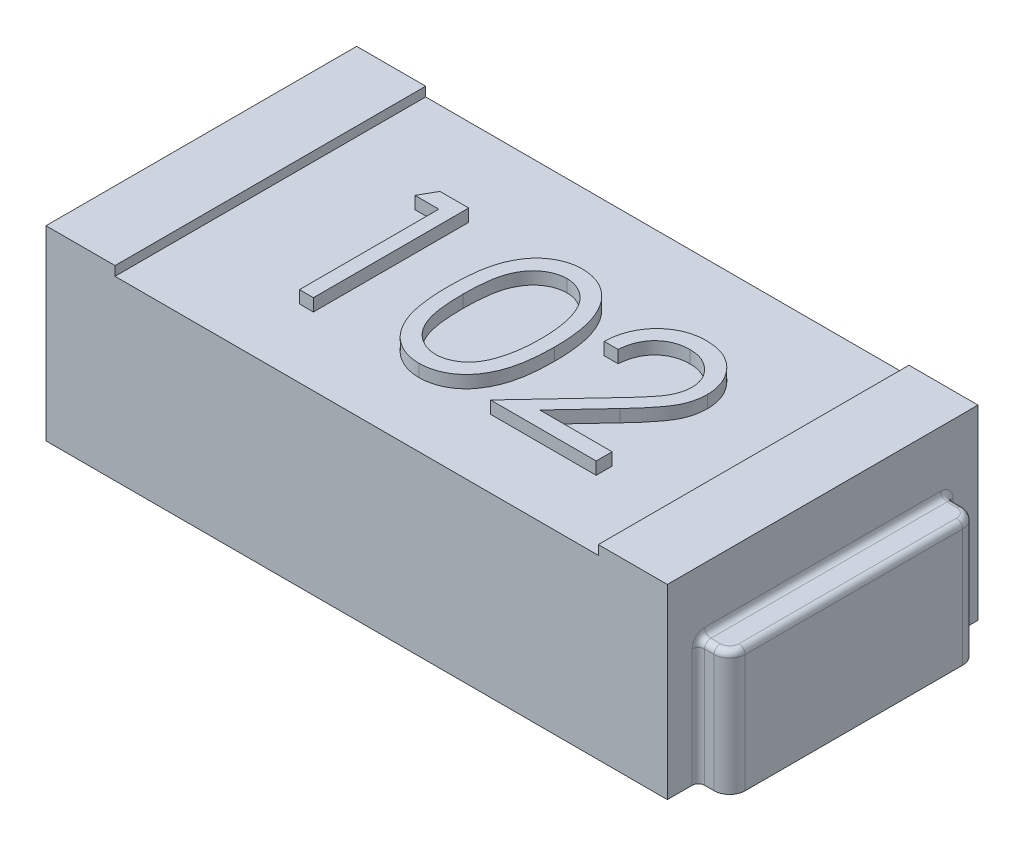
from build123d import *

# Parameters (mm, degrees)
ESQUISSE1_W             = 2
ESQUISSE1_H             = 1
BOSS_EXTRU_1_DEPTH      = 0.6
ESQUISSE2_W             = 1.555645222
ESQUISSE2_H             = 1
ENL_V_MAT_EXTRU_1_DEPTH = 0.03
BOSS_EXTRU_2_DEPTH      = 0.4
CONG_1_R                = 0.02
CONG_1_OF_SYM_TRIE2_R   = 0.02
BOSS_EXTRU_3_DEPTH      = 0.04


with BuildPart() as part:
    # Esquisse1 → Boss.-Extru.1 (new body)
    with BuildSketch(Plane(origin=(0, 0, 0), x_dir=(1, 0, 0), z_dir=(0, 1, 0))):
        Rectangle(ESQUISSE1_W, ESQUISSE1_H)
    extrude(amount=BOSS_EXTRU_1_DEPTH)

    # Esquisse2 → Enlèv. mat.-Extru.1 (cut)
    with BuildSketch(Plane(origin=(0, 0.6, 0), x_dir=(1, 0, 0), z_dir=(0, 1, 0))):
        Rectangle(ESQUISSE2_W, ESQUISSE2_H)
    extrude(amount=-ENL_V_MAT_EXTRU_1_DEPTH, mode=Mode.SUBTRACT)

    # Esquisse3 → Boss.-Extru.2 (add)
    with BuildSketch(Plane(origin=(0, 0, 0), x_dir=(1, 0, 0), z_dir=(0, 1, 0))):
        with BuildLine():
            Line((1, 0.4), (1.050552667, 0.4))
            ThreePointArc((1.050552667, 0.4), (1.085908006, 0.385355339), (1.100552667, 0.35))
            Line((1.100552667, 0.35), (1.100552667, -0.35))
            ThreePointArc((1.100552667, -0.35), (1.085908006, -0.385355339), (1.050552667, -0.4))
            Line((1.050552667, -0.4), (1, -0.4))
            Line((1, -0.4), (1, 0.4))
        make_face()
    boss_extru_2 = extrude(amount=BOSS_EXTRU_2_DEPTH)

    # Congé1
    cong_1_edges = [part.edges().sort_by_distance(p)[0] for p in [
        (1, 0.2, -0.4),
        (1, 0.2, 0.4),
        (1, 0.4, 0),
        (1.025276334, 0.4, 0.4),
        (1.085908006, 0.4, 0.385355339),
        (1.100552667, 0.4, 0),
        (1.085908006, 0.4, -0.385355339),
        (1.025276334, 0.4, -0.4),
    ]]
    fillet(cong_1_edges, radius=CONG_1_R)

    # Symétrie2: Boss.-Extru.2 across plane
    add(boss_extru_2.mirror(Plane(origin=(0, 0, 0), x_dir=(0, 0, 1), z_dir=(1, 0, 0))))

    # Congé1 of Symétrie2
    cong_1_of_sym_trie2_edges = [part.edges().sort_by_distance(p)[0] for p in [
        (-1, 0.2, -0.4),
        (-1, 0.2, 0.4),
        (-1, 0.4, 0),
        (-1.025276334, 0.4, 0.4),
        (-1.085908006, 0.4, 0.385355339),
        (-1.100552667, 0.4, 0),
        (-1.085908006, 0.4, -0.385355339),
        (-1.025276334, 0.4, -0.4),
    ]]
    fillet(cong_1_of_sym_trie2_edges, radius=CONG_1_OF_SYM_TRIE2_R)

    # Esquisse4 → Boss.-Extru.3 (add)
    with BuildSketch(Plane(origin=(0, 0.57, 0), x_dir=(1, 0, 0), z_dir=(0, 1, 0))):
        with BuildLine():
            Line((0.275641026, 0.065854324), (0.230769231, 0.065854324))
            add(Edge.make_bspline(
                [(0.230769231, 0.065854324), (0.231061681, 0.071807307), (0.231636046, 0.08349881), (0.234325802, 0.100545082), (0.238174498, 0.116838625), (0.243616135, 0.132248612), (0.250374174, 0.146911299), (0.258478464, 0.160768444), (0.268077586, 0.173767185), (0.278964262, 0.18578702), (0.290788353, 0.196813816), (0.303546344, 0.206335994), (0.316952777, 0.214381375), (0.330966977, 0.221107267), (0.345747057, 0.226155816), (0.361158894, 0.229901765), (0.377270199, 0.232155528), (0.388247345, 0.232397784), (0.393830128, 0.23252099)],
                knots=[0, 0, 0, 0, 1.7869e-05, 3.5094e-05, 5.1686e-05, 6.8032e-05, 8.4031e-05, 0.000100058, 0.000116104, 0.000132416, 0.000148647, 0.000164532, 0.000180078, 0.00019549, 0.000211074, 0.000226841, 0.000243017, 0.000259759, 0.000259759, 0.000259759, 0.000259759], degree=3))
            add(Edge.make_bspline(
                [(0.393830128, 0.23252099), (0.39931271, 0.232392639), (0.410085788, 0.232140434), (0.425808933, 0.229974573), (0.440777118, 0.226582346), (0.454961085, 0.221823), (0.468247665, 0.215425225), (0.480736672, 0.207739862), (0.492576787, 0.198851315), (0.503234899, 0.188386485), (0.513021768, 0.177214715), (0.521464947, 0.165287872), (0.528695399, 0.152969403), (0.53472221, 0.140165374), (0.539158802, 0.126755227), (0.542527117, 0.112934198), (0.544431033, 0.098559225), (0.544723237, 0.088829717), (0.544871795, 0.08388317)],
                knots=[0, 0, 0, 0, 1.6441e-05, 3.2306e-05, 4.7516e-05, 6.2435e-05, 7.7085e-05, 9.1652e-05, 0.000106376, 0.000121393, 0.000136374, 0.000150882, 0.000165157, 0.000179183, 0.000193247, 0.000207458, 0.000221808, 0.000236648, 0.000236648, 0.000236648, 0.000236648], degree=3))
            add(Edge.make_bspline(
                [(0.544871795, 0.08388317), (0.5446299, 0.076919193), (0.544150356, 0.063113449), (0.540048302, 0.042825611), (0.533641657, 0.023169408), (0.525927749, 0.007349794), (0.518145972, -0.005397848), (0.511133471, -0.015893378), (0.502924212, -0.027194159), (0.493398712, -0.03926235), (0.482754016, -0.052192479), (0.470893707, -0.065976736), (0.45773321, -0.080472703), (0.448496281, -0.090373503), (0.443709936, -0.09550385)],
                knots=[0, 0, 0, 0, 2.0874e-05, 4.1382e-05, 6.1843e-05, 8.2763e-05, 9.3997e-05, 0.000106637, 0.000120621, 0.000135888, 0.000152753, 0.000170863, 0.000190435, 0.000211484, 0.000211484, 0.000211484, 0.000211484], degree=3))
            Line((0.443709936, -0.09550385), (0.318609776, -0.229017471))
            Line((0.318609776, -0.229017471), (0.551282051, -0.229017471))
            Line((0.551282051, -0.229017471), (0.551282051, -0.280299523))
            Line((0.551282051, -0.280299523), (0.211538462, -0.280299523))
            Line((0.211538462, -0.280299523), (0.405448718, -0.073368433))
            add(Edge.make_bspline(
                [(0.405448718, -0.073368433), (0.410169845, -0.068440103), (0.419238163, -0.058973791), (0.432064245, -0.045153368), (0.443584101, -0.032332005), (0.4538723, -0.020533927), (0.462705658, -0.00958656), (0.470544548, 0.000155541), (0.476825347, 0.009120462), (0.483641832, 0.019511978), (0.490243829, 0.032199452), (0.495917023, 0.047704265), (0.499376287, 0.063665301), (0.499791263, 0.074451306), (0.5, 0.079876759)],
                knots=[0, 0, 0, 0, 2.0474e-05, 3.9327e-05, 5.6561e-05, 7.2184e-05, 8.6278e-05, 9.8762e-05, 0.000109683, 0.000119101, 0.000136035, 0.000152448, 0.000168517, 0.00018478, 0.00018478, 0.00018478, 0.00018478], degree=3))
            add(Edge.make_bspline(
                [(0.5, 0.079876759), (0.49990918, 0.083288388), (0.49973019, 0.090012052), (0.498150519, 0.099870018), (0.495763304, 0.109379277), (0.492342553, 0.11856908), (0.487827304, 0.12734703), (0.482331107, 0.135723813), (0.47598967, 0.143822236), (0.468653774, 0.151415565), (0.460594985, 0.158370023), (0.452081521, 0.164530606), (0.443074363, 0.169679051), (0.433611489, 0.17389955), (0.423719279, 0.177210319), (0.413378601, 0.179504402), (0.402618027, 0.180944757), (0.395270385, 0.181139638), (0.391526442, 0.181238939)],
                knots=[0, 0, 0, 0, 1.0229e-05, 2.0159e-05, 2.9876e-05, 3.9606e-05, 4.9505e-05, 5.9423e-05, 6.9622e-05, 8.0319e-05, 9.1042e-05, 0.000101521, 0.000111795, 0.000122107, 0.000132559, 0.000143032, 0.000153841, 0.00016507, 0.00016507, 0.00016507, 0.00016507], degree=3))
            add(Edge.make_bspline(
                [(0.391526442, 0.181238939), (0.387616323, 0.181136791), (0.379937495, 0.180936191), (0.368663348, 0.179532953), (0.357908237, 0.177112119), (0.347645108, 0.173801165), (0.337856595, 0.169592801), (0.328590303, 0.164351123), (0.319867034, 0.158096338), (0.311670387, 0.15100483), (0.30411839, 0.143109459), (0.297483122, 0.134308036), (0.291685406, 0.124761262), (0.286626944, 0.114494898), (0.282518988, 0.103415786), (0.279379967, 0.091563257), (0.276896132, 0.078988774), (0.276066343, 0.07030519), (0.275641026, 0.065854324)],
                knots=[0, 0, 0, 0, 1.1729e-05, 2.3035e-05, 3.4018e-05, 4.4756e-05, 5.5343e-05, 6.5928e-05, 7.6628e-05, 8.7492e-05, 9.8403e-05, 0.00010934, 0.000120489, 0.000131867, 0.000143625, 0.00015587, 0.000168619, 0.000182025, 0.000182025, 0.000182025, 0.000182025], degree=3))
        make_face()
        with BuildLine():
            add(Edge.make_bspline(
                [(-0.173076923, -0.030499843), (-0.173030063, -0.022485931), (-0.172939038, -0.00691879), (-0.171926406, 0.01576473), (-0.170244214, 0.037044772), (-0.167938875, 0.056922352), (-0.16513345, 0.075402605), (-0.16138838, 0.092436141), (-0.157129408, 0.108101799), (-0.152193345, 0.122450663), (-0.14662366, 0.13567605), (-0.140561623, 0.148022507), (-0.133766653, 0.159471354), (-0.126627094, 0.170205324), (-0.11885394, 0.180048709), (-0.110668399, 0.189140518), (-0.101750988, 0.197270626), (-0.092404844, 0.20467724), (-0.082545349, 0.211170022), (-0.07245354, 0.216888984), (-0.062059953, 0.22177468), (-0.051336213, 0.225616171), (-0.040378704, 0.228789149), (-0.029149123, 0.230958998), (-0.017628929, 0.232324271), (-0.009853009, 0.232454795), (-0.005909455, 0.23252099)],
                knots=[0, 0, 0, 0, 2.404e-05, 4.6699e-05, 6.8101e-05, 8.8066e-05, 0.000106723, 0.000124149, 0.000140356, 0.000155402, 0.000169633, 0.000183384, 0.000196628, 0.000209546, 0.000222029, 0.000234224, 0.000246203, 0.000258186, 0.000269964, 0.00028158, 0.000292962, 0.000304369, 0.000315719, 0.000327152, 0.000338644, 0.00035047, 0.00035047, 0.00035047, 0.00035047], degree=3))
            add(Edge.make_bspline(
                [(-0.005909455, 0.23252099), (-0.001932958, 0.232451302), (0.005975043, 0.232312715), (0.017666525, 0.230980723), (0.029087908, 0.228770563), (0.0401905, 0.225638995), (0.051065498, 0.221753898), (0.061627842, 0.21688431), (0.071943139, 0.211215901), (0.081847466, 0.204555347), (0.091449554, 0.197129307), (0.100513548, 0.18873464), (0.109040275, 0.179456109), (0.117136747, 0.169392986), (0.124573261, 0.158352259), (0.13165518, 0.146525958), (0.137994042, 0.133707263), (0.144098996, 0.120110053), (0.149368565, 0.105358102), (0.154120886, 0.089534565), (0.157960739, 0.072452538), (0.161159206, 0.054201646), (0.163637048, 0.034714862), (0.165441712, 0.01403396), (0.16639501, -0.007854667), (0.166574538, -0.022820074), (0.166666667, -0.030499843)],
                knots=[0, 0, 0, 0, 1.1926e-05, 2.3717e-05, 3.5247e-05, 4.6791e-05, 5.8292e-05, 6.9855e-05, 8.1646e-05, 9.3563e-05, 0.000105625, 0.000118029, 0.000130574, 0.000143401, 0.000156736, 0.000170478, 0.000184722, 0.000199611, 0.000215168, 0.000231679, 0.000249148, 0.000267657, 0.000287249, 0.00030806, 0.000329918, 0.000352958, 0.000352958, 0.000352958, 0.000352958], degree=3))
            add(Edge.make_bspline(
                [(0.166666667, -0.030499843), (0.166573583, -0.038146116), (0.166392214, -0.053044566), (0.165452398, -0.074834705), (0.163601165, -0.095405854), (0.161285453, -0.114807349), (0.158078172, -0.132958437), (0.154134577, -0.14992193), (0.14975596, -0.165771083), (0.144350989, -0.180376056), (0.138435173, -0.193940588), (0.131998717, -0.206607324), (0.125103027, -0.218488222), (0.117590349, -0.229488186), (0.109582719, -0.239685137), (0.100908749, -0.248899083), (0.091812951, -0.257352037), (0.082182606, -0.264873698), (0.072123813, -0.271457241), (0.061843945, -0.277344934), (0.051160605, -0.282092462), (0.040315897, -0.286168896), (0.029154702, -0.289283247), (0.017690932, -0.291436655), (0.005982898, -0.292946919), (-0.001931611, -0.29306213), (-0.005909455, -0.293120035)],
                knots=[0, 0, 0, 0, 2.294e-05, 4.4698e-05, 6.541e-05, 8.4889e-05, 0.0001033, 0.000120672, 0.000137126, 0.000152589, 0.000167346, 0.000181501, 0.000195192, 0.000208527, 0.000221432, 0.000234046, 0.00024645, 0.000258652, 0.000270653, 0.000282492, 0.000294147, 0.000305682, 0.000317226, 0.000328855, 0.000340657, 0.000352583, 0.000352583, 0.000352583, 0.000352583], degree=3))
            add(Edge.make_bspline(
                [(-0.005909455, -0.293120035), (-0.0098529, -0.293053413), (-0.017628604, -0.292922047), (-0.029150379, -0.291562943), (-0.040333585, -0.289377871), (-0.051233407, -0.286318356), (-0.061905766, -0.282573379), (-0.072205236, -0.277694282), (-0.082246333, -0.272075129), (-0.09200227, -0.265675783), (-0.101289721, -0.258344114), (-0.110160951, -0.25023493), (-0.118393096, -0.241145871), (-0.12605511, -0.231220454), (-0.133337123, -0.22054999), (-0.140035605, -0.208988794), (-0.146231441, -0.196582707), (-0.151894797, -0.183251577), (-0.156916034, -0.168800873), (-0.161351421, -0.153065276), (-0.164853444, -0.135905899), (-0.167851009, -0.117460561), (-0.170268778, -0.09765), (-0.171919396, -0.07646346), (-0.172939583, -0.053914145), (-0.173030308, -0.038447034), (-0.173076923, -0.030499843)],
                knots=[0, 0, 0, 0, 1.1826e-05, 2.3318e-05, 3.475e-05, 4.5977e-05, 5.7256e-05, 6.8638e-05, 8.0117e-05, 9.1757e-05, 0.000103599, 0.000115578, 0.000127773, 0.000140335, 0.00015317, 0.0001665, 0.000180386, 0.000194748, 0.000209921, 0.000226252, 0.000243755, 0.000262428, 0.000282305, 0.000303608, 0.000326166, 0.000350006, 0.000350006, 0.000350006, 0.000350006], degree=3))
        make_face()
        with BuildLine():
            add(Edge.make_bspline(
                [(-0.128205128, -0.030299523), (-0.128188064, -0.036977908), (-0.128154947, -0.049939343), (-0.127289775, -0.068774095), (-0.126111171, -0.086341285), (-0.124590985, -0.102663218), (-0.122333421, -0.117684649), (-0.11980388, -0.131508889), (-0.116725582, -0.14406278), (-0.113083436, -0.155432467), (-0.108934994, -0.165810906), (-0.104405585, -0.175468222), (-0.099539767, -0.184518499), (-0.094094174, -0.192880443), (-0.088163451, -0.200581323), (-0.081881557, -0.207757442), (-0.075014045, -0.214157011), (-0.06551351, -0.221832276), (-0.052971157, -0.229763581), (-0.037168234, -0.236670165), (-0.020929884, -0.241010516), (-0.009908277, -0.241562481), (-0.004407051, -0.241837984)],
                knots=[0, 0, 0, 0, 2.0033e-05, 3.888e-05, 5.6549e-05, 7.2854e-05, 8.8039e-05, 0.000102104, 0.000115004, 0.000126787, 0.000137891, 0.00014851, 0.000158774, 0.000168692, 0.000178408, 0.000187915, 0.000197268, 0.000206529, 0.000224535, 0.00024158, 0.000258123, 0.000274609, 0.000274609, 0.000274609, 0.000274609], degree=3))
            add(Edge.make_bspline(
                [(-0.004407051, -0.241837984), (0.001129759, -0.24160973), (0.012191948, -0.241153692), (0.028353919, -0.236753873), (0.044043957, -0.230115367), (0.056339949, -0.222265723), (0.065694598, -0.214790248), (0.072397025, -0.208416726), (0.078548746, -0.201280174), (0.084383328, -0.193580275), (0.089734625, -0.18516992), (0.094600787, -0.176089552), (0.099041266, -0.166313955), (0.101571129, -0.159489707), (0.102864583, -0.156000644)],
                knots=[0, 0, 0, 0, 1.6578e-05, 3.3121e-05, 4.9903e-05, 6.7548e-05, 7.6668e-05, 8.5806e-05, 9.5248e-05, 0.000104903, 0.000114767, 0.000125119, 0.000135787, 0.000146948, 0.000146948, 0.000146948, 0.000146948], degree=3))
            add(Edge.make_bspline(
                [(0.102864583, -0.156000644), (0.104371979, -0.151539253), (0.107432638, -0.142480715), (0.111377177, -0.128428765), (0.114483663, -0.113685513), (0.117278429, -0.098339068), (0.119186009, -0.082276253), (0.12072141, -0.06554677), (0.121625794, -0.048138004), (0.121737902, -0.036310148), (0.121794872, -0.030299523)],
                knots=[0, 0, 0, 0, 1.4127e-05, 2.8683e-05, 4.3751e-05, 5.9313e-05, 7.5463e-05, 9.2257e-05, 0.000109708, 0.00012774, 0.00012774, 0.00012774, 0.00012774], degree=3))
            add(Edge.make_bspline(
                [(0.121794872, -0.030299523), (0.121716273, -0.024289869), (0.121562518, -0.012533703), (0.120974805, 0.00468318), (0.119457152, 0.021035717), (0.117771564, 0.036594356), (0.115286246, 0.051272971), (0.11260656, 0.065194443), (0.109006386, 0.078186304), (0.105160704, 0.090451958), (0.100759219, 0.101852052), (0.095914114, 0.112439736), (0.090739577, 0.122266125), (0.085119257, 0.131304259), (0.079119874, 0.139594623), (0.072583081, 0.146970993), (0.065768171, 0.153661989), (0.056222858, 0.161299499), (0.043726531, 0.169086884), (0.028177153, 0.176253421), (0.011995633, 0.180368891), (0.001056568, 0.180949132), (-0.004407051, 0.181238939)],
                knots=[0, 0, 0, 0, 1.8031e-05, 3.5273e-05, 5.1659e-05, 6.7289e-05, 8.2207e-05, 9.6311e-05, 0.000109795, 0.000122624, 0.000134863, 0.000146427, 0.000157539, 0.000168156, 0.000178333, 0.000188198, 0.000197689, 0.00020695, 0.000224818, 0.00024172, 0.000258142, 0.000274528, 0.000274528, 0.000274528, 0.000274528], degree=3))
            add(Edge.make_bspline(
                [(-0.004407051, 0.181238939), (-0.009937136, 0.180948732), (-0.02100738, 0.18036779), (-0.037357087, 0.176268754), (-0.053029138, 0.169124045), (-0.06549242, 0.161273706), (-0.075044389, 0.153796804), (-0.081770488, 0.147313025), (-0.088077084, 0.140220703), (-0.093886756, 0.132449001), (-0.099328082, 0.124096805), (-0.104325369, 0.11509841), (-0.108827845, 0.105408216), (-0.112982779, 0.095034439), (-0.116636034, 0.083665733), (-0.119649458, 0.071127305), (-0.122433322, 0.057347035), (-0.124404075, 0.042244248), (-0.12615604, 0.025918226), (-0.127281947, 0.008307181), (-0.128157841, -0.01055916), (-0.12818905, -0.023587611), (-0.128205128, -0.030299523)],
                knots=[0, 0, 0, 0, 1.6586e-05, 3.3202e-05, 5.0195e-05, 6.8064e-05, 7.7262e-05, 8.6542e-05, 9.6049e-05, 0.000105705, 0.000115623, 0.000125935, 0.000136554, 0.000147658, 0.000159441, 0.000172341, 0.000186327, 0.000201596, 0.000218011, 0.00023558, 0.000254527, 0.000274661, 0.000274661, 0.000274661, 0.000274661], degree=3))
        make_face(mode=Mode.SUBTRACT)
        Polygon((-0.451422276, 0.219700477), (-0.358974359, 0.219700477), (-0.358974359, -0.280299523), (-0.403846154, -0.280299523), (-0.403846154, 0.168418426), (-0.480769231, 0.168418426), align=None)
    extrude(amount=BOSS_EXTRU_3_DEPTH)


solid = part.part
